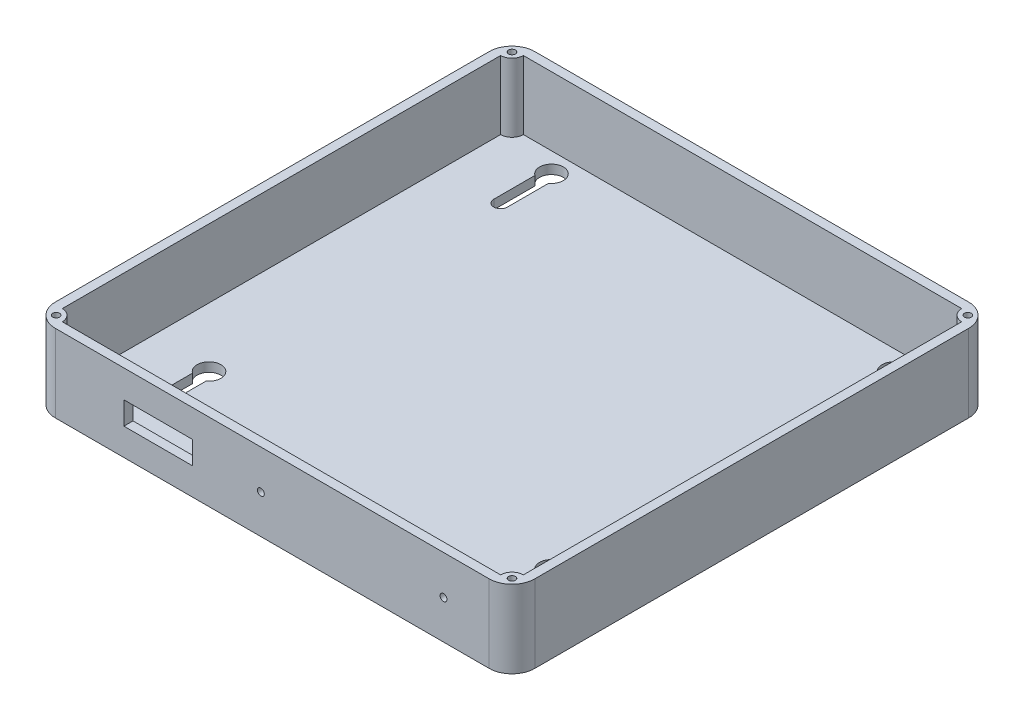
from build123d import *

# Parameters (mm, degrees)
SKETCH1_W            = 210
SKETCH1_H            = 210
BASE_DEPTH           = 4
WALLS_START          = 4
SKETCH1_3_W          = 210
SKETCH1_3_H          = 210
SKETCH1_3_W_2        = 202
SKETCH1_3_H_2        = 202
WALLS_DEPTH          = 30
SCREWMOUNTS_DEPTH    = 30
SKETCH2_5_R          = 1.5
SCREWHOLES_DEPTH     = 12.5
ROUNDEDCORNERS_R     = 10
BACKHOLEMOUNTS_DEPTH = 4
SKETCH4_R            = 1.5
SKETCH4_W            = 30
SKETCH4_H            = 10
BATTERYPACK_DEPTH    = 4


with BuildPart() as part:
    # Sketch1 → Base (new body)
    with BuildSketch(Plane(origin=(0, 0, 0), x_dir=(1, 0, 0), z_dir=(0, 1, 0))):
        Rectangle(SKETCH1_W, SKETCH1_H)
    extrude(amount=BASE_DEPTH)

    # Sketch1_3 → Walls (add)
    with BuildSketch(Plane(origin=(0, 0, 0), x_dir=(1, 0, 0), z_dir=(0, 1, 0)).offset(WALLS_START)):
        Rectangle(SKETCH1_3_W, SKETCH1_3_H)
        Rectangle(SKETCH1_3_W_2, SKETCH1_3_H_2, mode=Mode.SUBTRACT)
    extrude(amount=WALLS_DEPTH)

    # Sketch2 → ScrewMounts (add)
    with BuildSketch(Plane(origin=(0, 34, 0), x_dir=(1, 0, 0), z_dir=(0, 1, 0))):
        with BuildLine():
            Line((-101, 101), (-101, 96))
            ThreePointArc((-101, 96), (-97.464466094, 97.464466094), (-96, 101))
            Line((-96, 101), (-101, 101))
        make_face()
        with BuildLine():
            Line((-101, -101), (-96, -101))
            ThreePointArc((-96, -101), (-97.464466094, -97.464466094), (-101, -96))
            Line((-101, -96), (-101, -101))
        make_face()
        with BuildLine():
            Line((101, 101), (96, 101))
            ThreePointArc((96, 101), (97.464466094, 97.464466094), (101, 96))
            Line((101, 96), (101, 101))
        make_face()
        with BuildLine():
            Line((101, -101), (101, -96))
            ThreePointArc((101, -96), (97.464466094, -97.464466094), (96, -101))
            Line((96, -101), (101, -101))
        make_face()
    extrude(amount=-SCREWMOUNTS_DEPTH)

    # Sketch2_5 → ScrewHoles (cut)
    with BuildSketch(Plane(origin=(0, 34, 0), x_dir=(1, 0, 0), z_dir=(0, 1, 0))):
        with Locations((-99.833273811, 99.833273811)):
            Circle(SKETCH2_5_R)
        with Locations((-99.833273811, -99.833273811)):
            Circle(SKETCH2_5_R)
        with Locations((99.833273811, 99.833273811)):
            Circle(SKETCH2_5_R)
        with Locations((99.833273811, -99.833273811)):
            Circle(SKETCH2_5_R)
    extrude(amount=-SCREWHOLES_DEPTH, mode=Mode.SUBTRACT)

    # RoundedCorners
    roundedcorners_edges = [part.edges().sort_by_distance(p)[0] for p in [
        (-105, 17, 105),
        (105, 17, 105),
        (105, 17, -105),
        (-105, 17, -105),
    ]]
    fillet(roundedcorners_edges, radius=ROUNDEDCORNERS_R)

    # Sketch3 → BackHoleMounts (cut)
    with BuildSketch(Plane.XZ):
        with BuildLine():
            Line((-77.985, 80), (-77.985, 61.974012195))
            ThreePointArc((-77.985, 61.974012195), (-75, 52.505), (-72.015, 61.974012195))
            Line((-72.015, 61.974012195), (-72.015, 80))
            ThreePointArc((-72.015, 80), (-75, 82.985), (-77.985, 80))
        make_face()
        with BuildLine():
            Line((77.985, 80), (77.985, 61.974012195))
            ThreePointArc((77.985, 61.974012195), (75, 52.505), (72.015, 61.974012195))
            Line((72.015, 61.974012195), (72.015, 80))
            ThreePointArc((72.015, 80), (75, 82.985), (77.985, 80))
        make_face()
        with BuildLine():
            Line((72.015, -70), (72.015, -88.025987805))
            ThreePointArc((72.015, -88.025987805), (75, -97.495), (77.985, -88.025987805))
            Line((77.985, -88.025987805), (77.985, -70))
            ThreePointArc((77.985, -70), (75, -67.015), (72.015, -70))
        make_face()
        with BuildLine():
            Line((-77.985, -70), (-77.985, -88.025987805))
            ThreePointArc((-77.985, -88.025987805), (-75, -97.495), (-72.015, -88.025987805))
            Line((-72.015, -88.025987805), (-72.015, -70))
            ThreePointArc((-72.015, -70), (-75, -67.015), (-77.985, -70))
        make_face()
    extrude(amount=-BACKHOLEMOUNTS_DEPTH, mode=Mode.SUBTRACT)

    # Sketch4 → BatteryPack (cut)
    with BuildSketch(Plane.XY.offset(105)):
        with Locations((75, 16.9)):
            Circle(SKETCH4_R)
        with Locations((-5, 16.9)):
            Circle(SKETCH4_R)
        with Locations((-50, 16.9)):
            Rectangle(SKETCH4_W, SKETCH4_H)
    extrude(amount=-BATTERYPACK_DEPTH, mode=Mode.SUBTRACT)


solid = part.part
